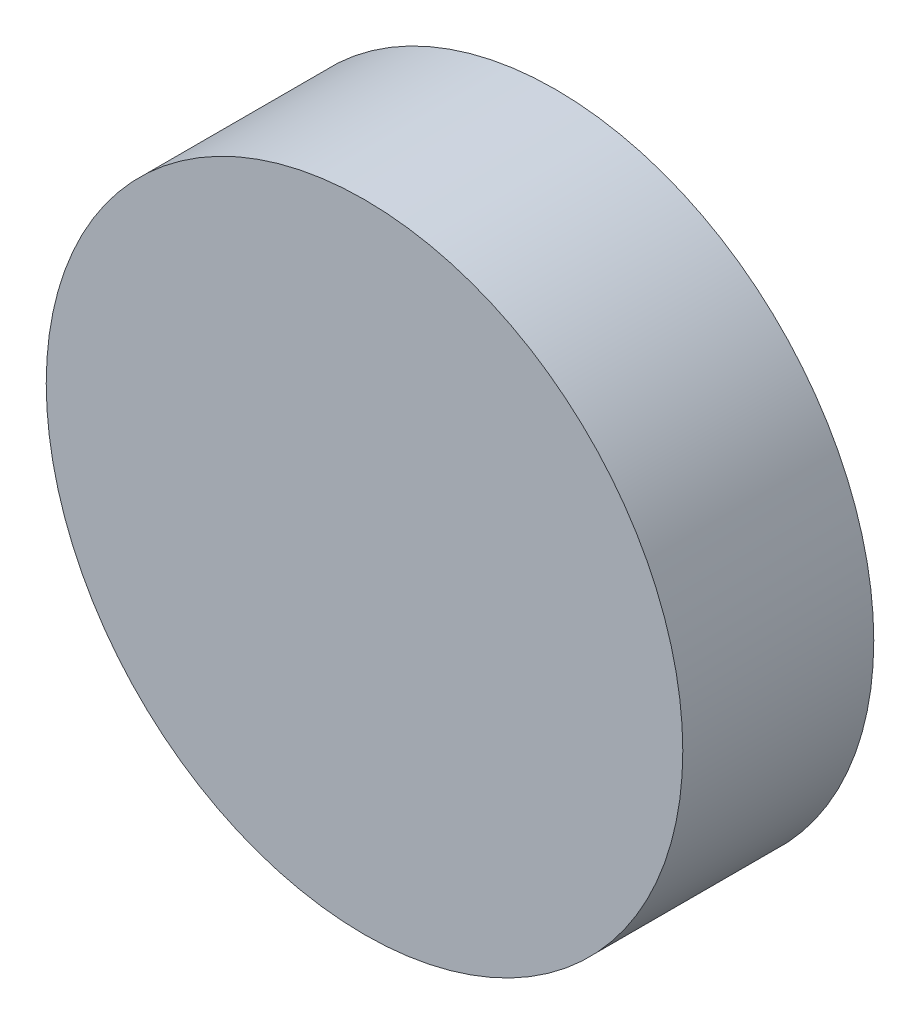
from build123d import *

# Parameters (mm, degrees)
BOSS_EXTRUDE1_DEPTH = 2
SKETCH2_R           = 10
BOSS_EXTRUDE2_DEPTH = 6
CUT_EXTRUDE1_DEPTH  = 2


with BuildPart() as part:
    # Sketch1 → Boss-Extrude1 (new body)
    with BuildSketch(Plane.XY):
        Polygon((-2.571996213, -4.179493846), (2.333549739, -4.317160982), (4.905545953, -0.137667136), (2.571996213, 4.179493846), (-2.333549739, 4.317160982), (-4.905545953, 0.137667136), align=None)
        Polygon((2.208890865, 3.589447656), (-2.004107423, 3.707679432), (-4.212998289, 0.118231775), (-2.208890865, -3.589447656), (2.004107423, -3.707679432), (4.212998289, -0.118231775), align=None, mode=Mode.SUBTRACT)
    extrude(amount=BOSS_EXTRUDE1_DEPTH)

    # Sketch2 → Boss-Extrude2 (add)
    with BuildSketch(Plane.XY.offset(2)):
        Circle(SKETCH2_R)
    extrude(amount=BOSS_EXTRUDE2_DEPTH)

    # Sketch5 → Cut-Extrude1 (cut)
    with BuildSketch(Plane(origin=(0, 0, 2), x_dir=(-1, 0, 0), z_dir=(0, 0, -1))):
        Polygon((-2.208890865, 3.589447656), (-4.212998289, -0.118231775), (-2.004107423, -3.707679432), (2.208890865, -3.589447656), (4.212998289, 0.118231775), (2.004107423, 3.707679432), align=None)
    extrude(amount=-CUT_EXTRUDE1_DEPTH, mode=Mode.SUBTRACT)


solid = part.part
